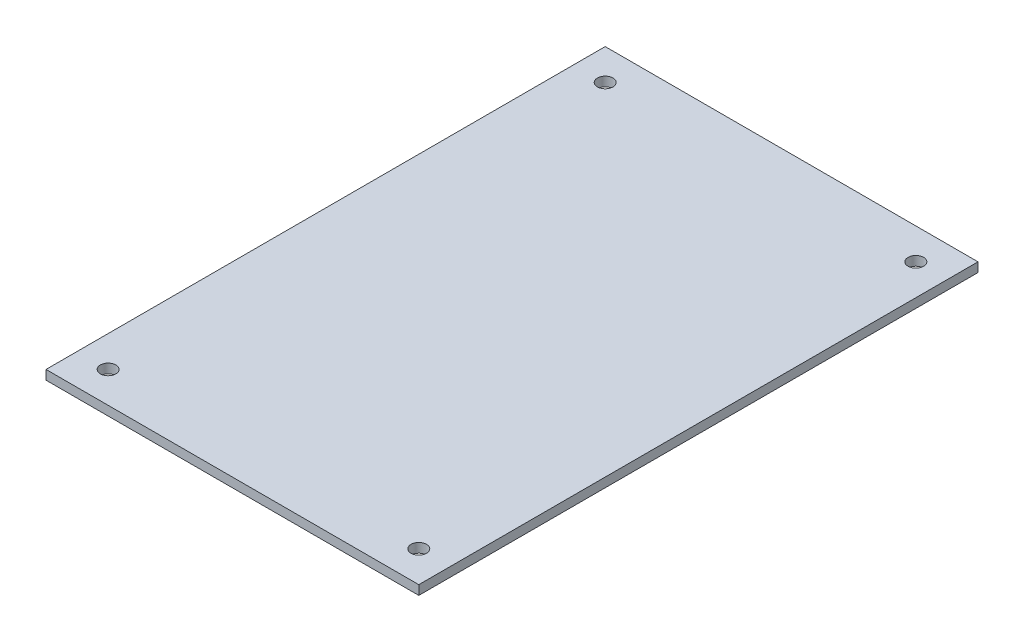
from build123d import *

# Parameters (mm, degrees)
SKETCH1_W           = 120
SKETCH1_H           = 180
SKETCH1_R           = 2.5
BOSS_EXTRUDE1_DEPTH = 3


with BuildPart() as part:
    # Sketch1 → Boss-Extrude1 (new body)
    with BuildSketch(Plane(origin=(0, 0, 0), x_dir=(1, 0, 0), z_dir=(0, 1, 0))):
        Rectangle(SKETCH1_W, SKETCH1_H)
        with Locations((-50, 80)):
            Circle(SKETCH1_R, mode=Mode.SUBTRACT)
        with Locations((50, 80)):
            Circle(SKETCH1_R, mode=Mode.SUBTRACT)
        with Locations((50, -80)):
            Circle(SKETCH1_R, mode=Mode.SUBTRACT)
        with Locations((-50, -80)):
            Circle(SKETCH1_R, mode=Mode.SUBTRACT)
    extrude(amount=BOSS_EXTRUDE1_DEPTH)


solid = part.part
